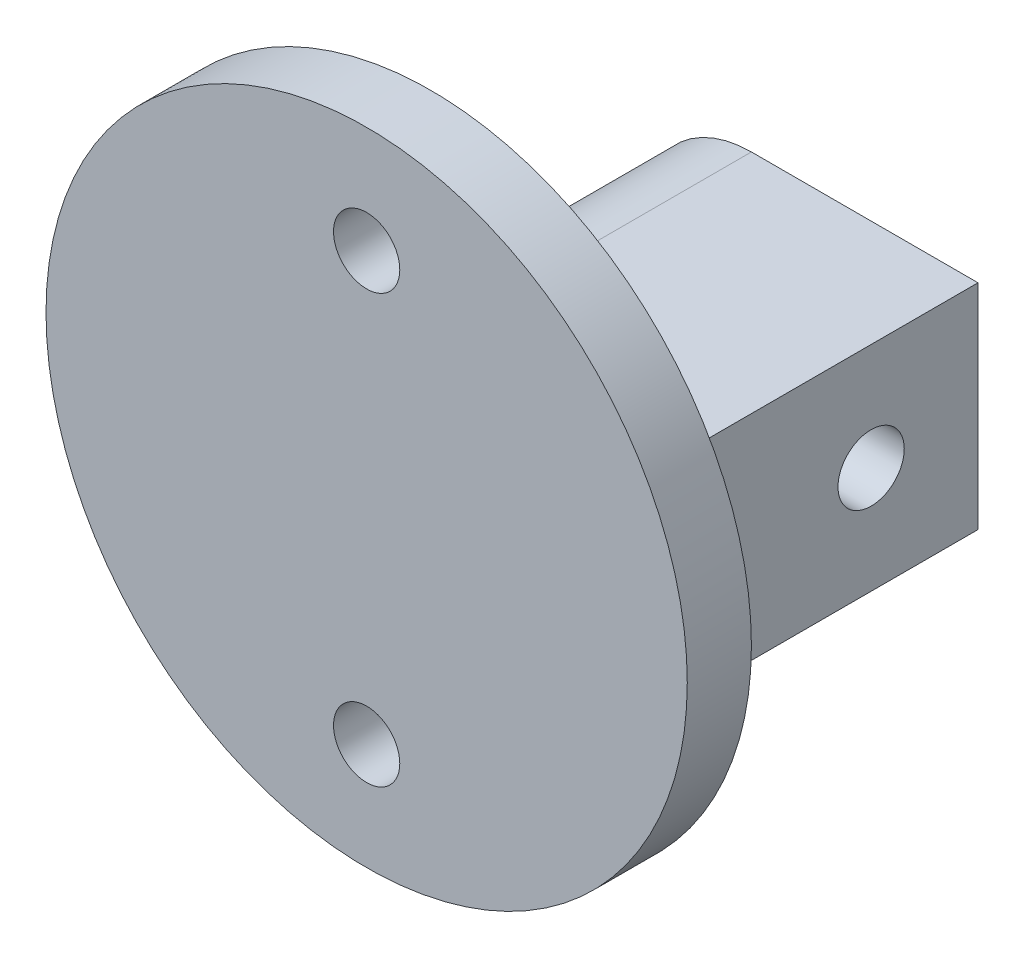
from build123d import *

# Parameters (mm, degrees)
SKETCH1_R           = 5
BOSS_EXTRUDE1_DEPTH = 15
SKETCH2_R           = 15
SKETCH2_R_2         = 1.55
BOSS_EXTRUDE3_DEPTH = 3
SKETCH4_R           = 2.6
CUT_EXTRUDE2_DEPTH  = 15
BOSS_EXTRUDE7_DEPTH = 15
SKETCH14_W          = 2.6
SKETCH14_H          = 5.7
CUT_EXTRUDE7_DEPTH  = 8.3
CUT_EXTRUDE8_REACH  = 27.6
SKETCH15_R          = 1.55


with BuildPart() as part:
    # Sketch1 → Boss-Extrude1 (new body)
    with BuildSketch(Plane.XY):
        Circle(SKETCH1_R)
    extrude(amount=BOSS_EXTRUDE1_DEPTH)

    # Sketch2 → Boss-Extrude3 (add)
    with BuildSketch(Plane.XY.offset(15)):
        Circle(SKETCH2_R)
        with Locations((0, 10)):
            Circle(SKETCH2_R_2, mode=Mode.SUBTRACT)
        with Locations((0, -10)):
            Circle(SKETCH2_R_2, mode=Mode.SUBTRACT)
    extrude(amount=BOSS_EXTRUDE3_DEPTH)

    # Sketch4 → Cut-Extrude2 (cut)
    with BuildSketch(Plane(origin=(0, 0, 0), x_dir=(-1, 0, 0), z_dir=(0, 0, -1))):
        Circle(SKETCH4_R)
    extrude(amount=-CUT_EXTRUDE2_DEPTH, mode=Mode.SUBTRACT)

    # Sketch13 → Boss-Extrude7 (add)
    with BuildSketch(Plane(origin=(0, 0, 15), x_dir=(-1, 0, 0), z_dir=(0, 0, -1))):
        with BuildLine():
            Line((-10.6, 5), (-10.6, -5))
            Line((-10.6, -5), (0, -5))
            ThreePointArc((0, -5), (-5, 0), (0, 5))
            Line((0, 5), (-10.6, 5))
        make_face()
    extrude(amount=BOSS_EXTRUDE7_DEPTH)

    # Sketch14 → Cut-Extrude7 (cut)
    with BuildSketch(Plane(origin=(0, 0, 0), x_dir=(-1, 0, 0), z_dir=(0, 0, -1))):
        with Locations((-6.3, 0)):
            Rectangle(SKETCH14_W, SKETCH14_H)
    extrude(amount=-CUT_EXTRUDE7_DEPTH, mode=Mode.SUBTRACT)

    # Cut-Extrude8: up to this face of the body
    cut_extrude8_end = part.part.faces().sort_by_distance((2.6, 0, 7.5))[0]
    # Sketch15 → Cut-Extrude8 (cut, up to the picked face)
    with BuildSketch(Plane(origin=(10.6, 0, 0), x_dir=(0, 0, -1), z_dir=(1, 0, 0)), mode=Mode.PRIVATE) as cut_extrude8_sk1:
        with Locations((-5, 0)):
            Circle(SKETCH15_R)
    cut_extrude8_tool1 = split(extrude(cut_extrude8_sk1.sketch, amount=-CUT_EXTRUDE8_REACH, mode=Mode.PRIVATE), bisect_by=cut_extrude8_end, keep=Keep.BOTH, mode=Mode.PRIVATE)
    add(cut_extrude8_tool1.solids().sort_by_distance((10.6, 0, 5))[0], mode=Mode.SUBTRACT)


solid = part.part
